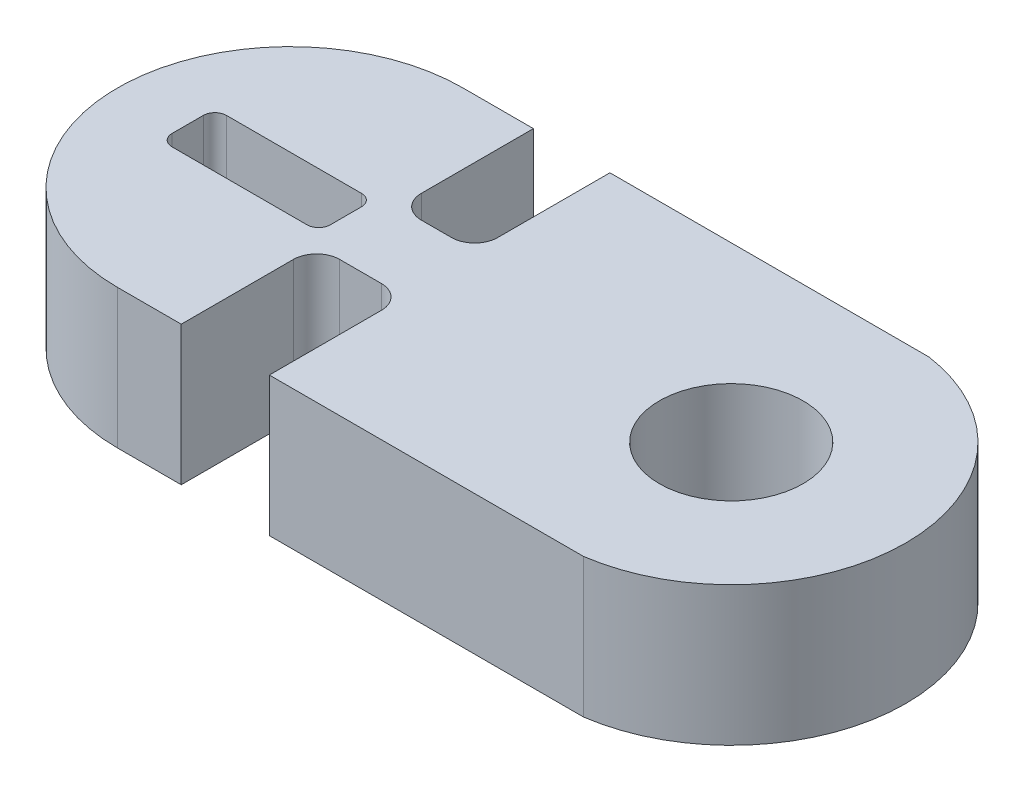
from build123d import *

# Parameters (mm, degrees)
CROQUIS1_R              = 3.1
SALIENTE_EXTRUIR1_DEPTH = 6
CROQUIS2_W              = 6.826394781
CROQUIS2_H              = 2.350070334
CORTAR_EXTRUIR1_DEPTH   = 7
REDONDEO1_R             = 1
REDONDEO2_R             = 0.5


with BuildPart() as part:
    # Croquis1 → Saliente-Extruir1 (new body)
    with BuildSketch(Plane(origin=(0, 0, 0), x_dir=(1, 0, 0), z_dir=(0, 1, 0))):
        with BuildLine():
            Line((-10.05, 7.45), (-7.01, 7.45))
            Line((-7.01, 7.45), (-7.01, 1.614093831))
            Line((-7.01, 1.614093831), (-3.71, 1.614093831))
            Line((-3.71, 1.614093831), (-3.71, 7.45))
            Line((-3.71, 7.45), (10.05, 7.45))
            ThreePointArc((10.05, 7.45), (16.5, 0), (10.05, -7.45))
            Line((10.05, -7.45), (-3.5, -7.45))
            Line((-3.5, -7.45), (-3.5, -1.614093831))
            Line((-3.5, -1.614093831), (-7.3, -1.614093831))
            Line((-7.3, -1.614093831), (-7.3, -7.45))
            Line((-7.3, -7.45), (-10.05, -7.45))
            ThreePointArc((-10.05, -7.45), (-17.5, 0), (-10.05, 7.45))
        make_face()
        with Locations((8.97248062, 0)):
            Circle(CROQUIS1_R, mode=Mode.SUBTRACT)
    extrude(amount=SALIENTE_EXTRUIR1_DEPTH)

    # Croquis2 → Cortar-Extruir1 (cut)
    with BuildSketch(Plane(origin=(0, 6, 0), x_dir=(1, 0, 0), z_dir=(0, 1, 0))):
        with Locations((-11.209462468, 0.149210815)):
            Rectangle(CROQUIS2_W, CROQUIS2_H)
    extrude(amount=-CORTAR_EXTRUIR1_DEPTH, mode=Mode.SUBTRACT)

    # Redondeo1
    redondeo1_edges = [part.edges().sort_by_distance(p)[0] for p in [
        (-7.01, 3, -1.614093831),
        (-3.71, 3, -1.614093831),
        (-3.5, 3, 1.614093831),
        (-7.3, 3, 1.614093831),
    ]]
    fillet(redondeo1_edges, radius=REDONDEO1_R)

    # Redondeo2
    redondeo2_edges = [part.edges().sort_by_distance(p)[0] for p in [
        (-7.796265078, 3, -1.324245982),
        (-7.796265078, 3, 1.025824352),
        (-14.622659859, 3, 1.025824352),
        (-14.622659859, 3, -1.324245982),
    ]]
    fillet(redondeo2_edges, radius=REDONDEO2_R)


solid = part.part
